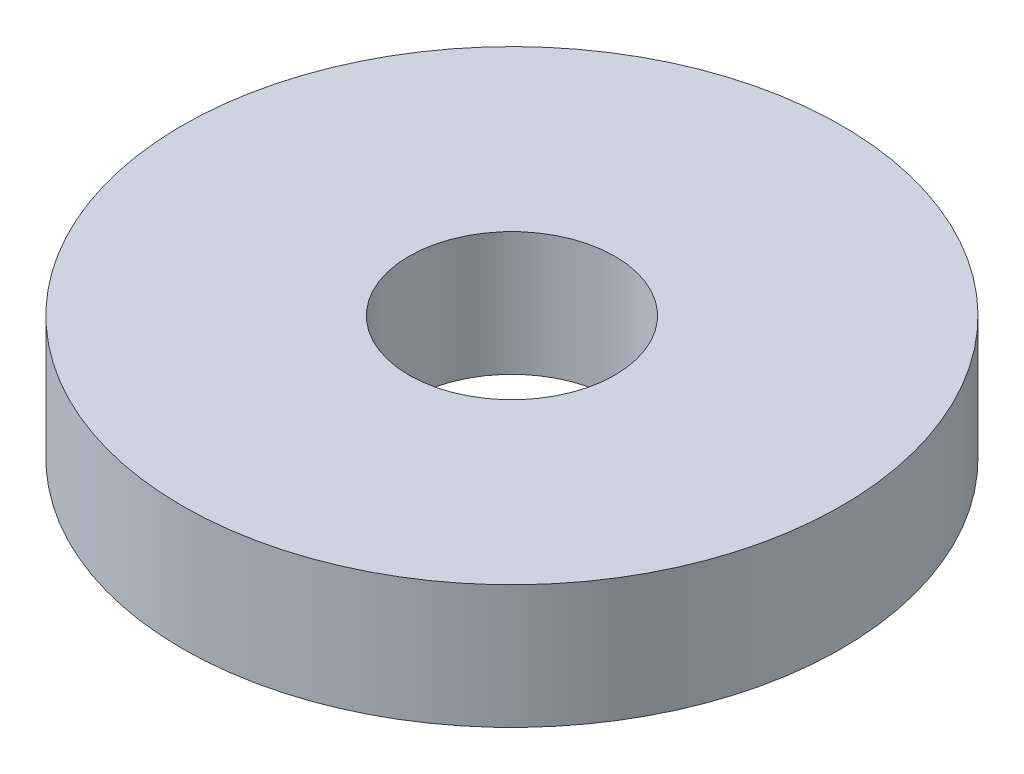
from build123d import *

# Parameters (mm, degrees)
SKETCH1_R           = 10.16
SKETCH1_R_2         = 3.175
BOSS_EXTRUDE1_DEPTH = 3.81


with BuildPart() as part:
    # Sketch1 → Boss-Extrude1 (new body)
    with BuildSketch(Plane(origin=(0, 0, 0), x_dir=(1, 0, 0), z_dir=(0, 1, 0))):
        Circle(SKETCH1_R)
        Circle(SKETCH1_R_2, mode=Mode.SUBTRACT)
    extrude(amount=BOSS_EXTRUDE1_DEPTH)


solid = part.part
